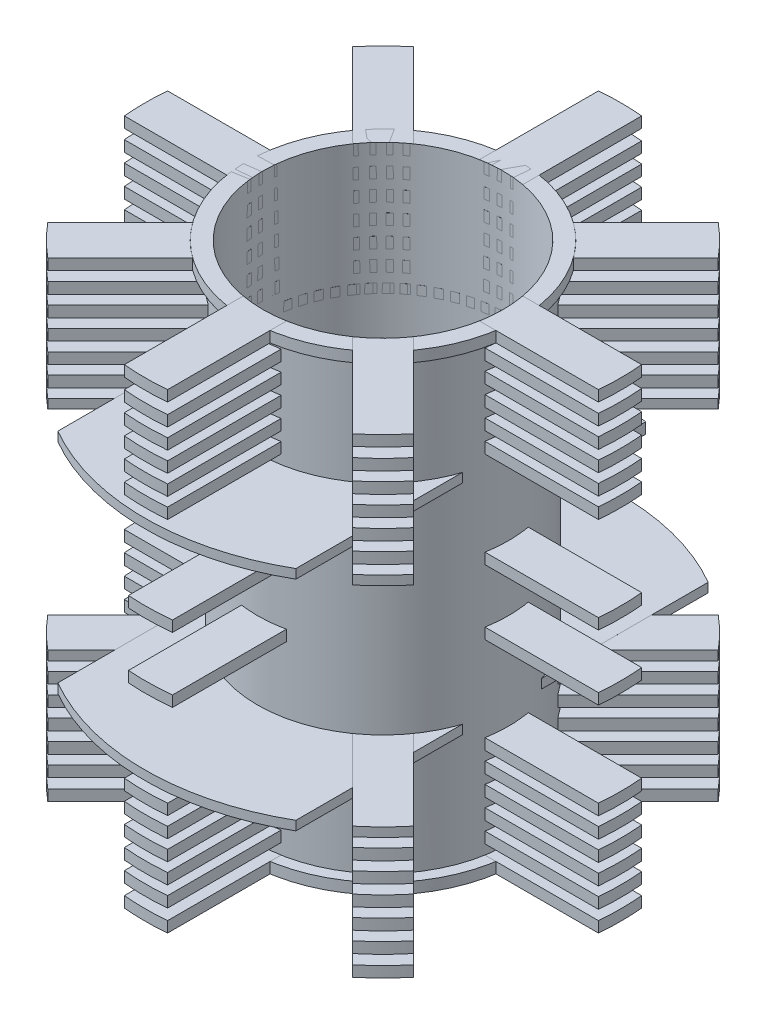
from build123d import *

# Parameters (mm, degrees)
SKETCH1_R                    = 12.6
SKETCH1_R_2                  = 11.1
BOSS_EXTRUDE1_DEPTH          = 1
SKETCH1_3_R                  = 11.6
SKETCH1_3_R_2                = 11.1
BOSS_EXTRUDE2_DEPTH          = 42
BOSS_EXTRUDE7_START          = -11.6
SKETCH8_W                    = 4
SKETCH8_H                    = 1
BOSS_EXTRUDE7_DEPTH          = 24
BOSS_EXTRUDE7_DEPTH_BACK     = 24
SKETCH8_W_2                  = 22
SKETCH8_H_2                  = 0.85
BOSS_EXTRUDE7_2_DEPTH        = 24
BOSS_EXTRUDE7_2_DEPTH_BACK   = 24
BOSS_EXTRUDE7_3_DEPTH        = 24
BOSS_EXTRUDE7_3_DEPTH_BACK   = 24
BOSS_EXTRUDE7_4_DEPTH        = 24
BOSS_EXTRUDE7_4_DEPTH_BACK   = 24
BOSS_EXTRUDE7_5_DEPTH        = 24
BOSS_EXTRUDE7_5_DEPTH_BACK   = 24
BOSS_EXTRUDE7_6_DEPTH        = 24
BOSS_EXTRUDE7_6_DEPTH_BACK   = 24
BOSS_EXTRUDE7_7_DEPTH        = 24
BOSS_EXTRUDE7_7_DEPTH_BACK   = 24
BOSS_EXTRUDE7_8_DEPTH        = 24
BOSS_EXTRUDE7_8_DEPTH_BACK   = 24
BOSS_EXTRUDE7_9_DEPTH        = 24
BOSS_EXTRUDE7_9_DEPTH_BACK   = 24
BOSS_EXTRUDE7_10_DEPTH       = 24
BOSS_EXTRUDE7_10_DEPTH_BACK  = 24
BOSS_EXTRUDE7_11_DEPTH       = 24
BOSS_EXTRUDE7_11_DEPTH_BACK  = 24
BOSS_EXTRUDE7_12_DEPTH       = 24
BOSS_EXTRUDE7_12_DEPTH_BACK  = 24
BOSS_EXTRUDE7_13_DEPTH       = 24
BOSS_EXTRUDE7_13_DEPTH_BACK  = 24
BOSS_EXTRUDE7_14_DEPTH       = 24
BOSS_EXTRUDE7_14_DEPTH_BACK  = 24
BOSS_EXTRUDE7_15_DEPTH       = 24
BOSS_EXTRUDE7_15_DEPTH_BACK  = 24
BOSS_EXTRUDE7_16_DEPTH       = 24
BOSS_EXTRUDE7_16_DEPTH_BACK  = 24
SKETCH11_W                   = 4
SKETCH11_H                   = 1
BOSS_EXTRUDE8_DEPTH          = 25
BOSS_EXTRUDE8_DEPTH_BACK     = 25
SKETCH11_H_2                 = 1.02
BOSS_EXTRUDE8_2_DEPTH        = 25
BOSS_EXTRUDE8_2_DEPTH_BACK   = 25
BOSS_EXTRUDE8_3_DEPTH        = 25
BOSS_EXTRUDE8_3_DEPTH_BACK   = 25
BOSS_EXTRUDE8_4_DEPTH        = 25
BOSS_EXTRUDE8_4_DEPTH_BACK   = 25
BOSS_EXTRUDE8_5_DEPTH        = 25
BOSS_EXTRUDE8_5_DEPTH_BACK   = 25
BOSS_EXTRUDE8_6_DEPTH        = 25
BOSS_EXTRUDE8_6_DEPTH_BACK   = 25
BOSS_EXTRUDE8_7_DEPTH        = 25
BOSS_EXTRUDE8_7_DEPTH_BACK   = 25
BOSS_EXTRUDE8_8_DEPTH        = 25
BOSS_EXTRUDE8_8_DEPTH_BACK   = 25
BOSS_EXTRUDE8_9_DEPTH        = 25
BOSS_EXTRUDE8_9_DEPTH_BACK   = 25
BOSS_EXTRUDE8_10_DEPTH       = 25
BOSS_EXTRUDE8_10_DEPTH_BACK  = 25
BOSS_EXTRUDE8_11_DEPTH       = 25
BOSS_EXTRUDE8_11_DEPTH_BACK  = 25
BOSS_EXTRUDE8_12_DEPTH       = 25
BOSS_EXTRUDE8_12_DEPTH_BACK  = 25
BOSS_EXTRUDE8_13_DEPTH       = 25
BOSS_EXTRUDE8_13_DEPTH_BACK  = 25
BOSS_EXTRUDE8_14_DEPTH       = 25
BOSS_EXTRUDE8_14_DEPTH_BACK  = 25
BOSS_EXTRUDE6_START          = 41.5
SKETCH1_8_R                  = 12.6
SKETCH1_8_R_2                = 11.1
BOSS_EXTRUDE6_DEPTH          = 1
SKETCH35_W                   = 4
SKETCH35_H                   = 1.02
SKETCH35_H_2                 = 1
SKETCH35_H_3                 = 0.85
BOSS_EXTRUDE12_DEPTH         = 25
BOSS_EXTRUDE12_DEPTH_BACK    = 25
SKETCH36_W                   = 4
SKETCH36_H                   = 1.02
BOSS_EXTRUDE13_DEPTH         = 25
BOSS_EXTRUDE13_DEPTH_BACK    = 25
BOSS_EXTRUDE13_2_DEPTH       = 25
BOSS_EXTRUDE13_2_DEPTH_BACK  = 25
BOSS_EXTRUDE13_3_DEPTH       = 25
BOSS_EXTRUDE13_3_DEPTH_BACK  = 25
BOSS_EXTRUDE13_4_DEPTH       = 25
BOSS_EXTRUDE13_4_DEPTH_BACK  = 25
BOSS_EXTRUDE13_5_DEPTH       = 25
BOSS_EXTRUDE13_5_DEPTH_BACK  = 25
SKETCH36_H_2                 = 1
BOSS_EXTRUDE13_6_DEPTH       = 25
BOSS_EXTRUDE13_6_DEPTH_BACK  = 25
SKETCH36_H_3                 = 0.85
BOSS_EXTRUDE13_7_DEPTH       = 25
BOSS_EXTRUDE13_7_DEPTH_BACK  = 25
BOSS_EXTRUDE13_8_DEPTH       = 25
BOSS_EXTRUDE13_8_DEPTH_BACK  = 25
BOSS_EXTRUDE13_9_DEPTH       = 25
BOSS_EXTRUDE13_9_DEPTH_BACK  = 25
BOSS_EXTRUDE13_10_DEPTH      = 25
BOSS_EXTRUDE13_10_DEPTH_BACK = 25
BOSS_EXTRUDE13_11_DEPTH      = 25
BOSS_EXTRUDE13_11_DEPTH_BACK = 25
BOSS_EXTRUDE13_12_DEPTH      = 25
BOSS_EXTRUDE13_12_DEPTH_BACK = 25
BOSS_EXTRUDE13_13_DEPTH      = 25
BOSS_EXTRUDE13_13_DEPTH_BACK = 25
BOSS_EXTRUDE13_14_DEPTH      = 25
BOSS_EXTRUDE13_14_DEPTH_BACK = 25
SKETCH37_R                   = 55.053371744
SKETCH37_R_2                 = 22
CUT_EXTRUDE11_DEPTH          = 1
CUT_EXTRUDE11_DEPTH_BACK     = 44.500303563
SKETCH37_6_R                 = 11.1
CUT_EXTRUDE12_DEPTH          = 1
CUT_EXTRUDE12_DEPTH_BACK     = 44.500303563


with BuildPart() as part:
    # Sketch1 (on Top Plane) → Boss-Extrude1 (new body)
    with BuildSketch(Plane(origin=(0, 0, 0), x_dir=(1, 0, 0), z_dir=(0, 1, 0))):
        Circle(SKETCH1_R)
        Circle(SKETCH1_R_2, mode=Mode.SUBTRACT)
    extrude(amount=-BOSS_EXTRUDE1_DEPTH)

    # Sketch1_3 (on Top Plane) → Boss-Extrude2 (add)
    with BuildSketch(Plane(origin=(0, 0, 0), x_dir=(1, 0, 0), z_dir=(0, 1, 0))):
        Circle(SKETCH1_3_R)
        Circle(SKETCH1_3_R_2, mode=Mode.SUBTRACT)
    extrude(amount=BOSS_EXTRUDE2_DEPTH)


with BuildPart() as body_2:
    # Sketch8 → Boss-Extrude7 (new body, two sides)
    with BuildSketch(Plane(origin=(0, 42, 11.6), x_dir=(1, 0, 0), z_dir=(0, 0, 1)).offset(BOSS_EXTRUDE7_START)) as boss_extrude7_sk:
        with Locations((0.415077538, -18.25)):
            Rectangle(SKETCH8_W, SKETCH8_H)
    extrude(amount=BOSS_EXTRUDE7_DEPTH)
    extrude(boss_extrude7_sk.sketch, amount=-BOSS_EXTRUDE7_DEPTH_BACK)


with BuildPart() as body_3:
    # Sketch8 → Boss-Extrude7 2 (new body, two sides)
    with BuildSketch(Plane(origin=(0, 42, 11.6), x_dir=(1, 0, 0), z_dir=(0, 0, 1)).offset(BOSS_EXTRUDE7_START)) as boss_extrude7_2_sk:
        with Locations((0, -11.175)):
            Rectangle(SKETCH8_W_2, SKETCH8_H_2)
    extrude(amount=BOSS_EXTRUDE7_2_DEPTH)
    extrude(boss_extrude7_2_sk.sketch, amount=-BOSS_EXTRUDE7_2_DEPTH_BACK)


with BuildPart() as body_4:
    # Sketch8 → Boss-Extrude7 3 (new body, two sides)
    with BuildSketch(Plane(origin=(0, 42, 11.6), x_dir=(1, 0, 0), z_dir=(0, 0, 1)).offset(BOSS_EXTRUDE7_START)) as boss_extrude7_3_sk:
        with Locations((0, -9.4)):
            Rectangle(SKETCH8_W, SKETCH8_H)
    extrude(amount=BOSS_EXTRUDE7_3_DEPTH)
    extrude(boss_extrude7_3_sk.sketch, amount=-BOSS_EXTRUDE7_3_DEPTH_BACK)


with BuildPart() as body_5:
    # Sketch8 → Boss-Extrude7 4 (new body, two sides)
    with BuildSketch(Plane(origin=(0, 42, 11.6), x_dir=(1, 0, 0), z_dir=(0, 0, 1)).offset(BOSS_EXTRUDE7_START)) as boss_extrude7_4_sk:
        with Locations((0, -31.325)):
            Rectangle(SKETCH8_W_2, SKETCH8_H_2)
    extrude(amount=BOSS_EXTRUDE7_4_DEPTH)
    extrude(boss_extrude7_4_sk.sketch, amount=-BOSS_EXTRUDE7_4_DEPTH_BACK)


with BuildPart() as body_6:
    # Sketch8 → Boss-Extrude7 5 (new body, two sides)
    with BuildSketch(Plane(origin=(0, 42, 11.6), x_dir=(1, 0, 0), z_dir=(0, 0, 1)).offset(BOSS_EXTRUDE7_START)) as boss_extrude7_5_sk:
        with Locations((0, -7.55)):
            Rectangle(SKETCH8_W, SKETCH8_H)
    extrude(amount=BOSS_EXTRUDE7_5_DEPTH)
    extrude(boss_extrude7_5_sk.sketch, amount=-BOSS_EXTRUDE7_5_DEPTH_BACK)


with BuildPart() as body_7:
    # Sketch8 → Boss-Extrude7 6 (new body, two sides)
    with BuildSketch(Plane(origin=(0, 42, 11.6), x_dir=(1, 0, 0), z_dir=(0, 0, 1)).offset(BOSS_EXTRUDE7_START)) as boss_extrude7_6_sk:
        with Locations((0, -5.7)):
            Rectangle(SKETCH8_W, SKETCH8_H)
    extrude(amount=BOSS_EXTRUDE7_6_DEPTH)
    extrude(boss_extrude7_6_sk.sketch, amount=-BOSS_EXTRUDE7_6_DEPTH_BACK)


with BuildPart() as body_8:
    # Sketch8 → Boss-Extrude7 7 (new body, two sides)
    with BuildSketch(Plane(origin=(0, 42, 11.6), x_dir=(1, 0, 0), z_dir=(0, 0, 1)).offset(BOSS_EXTRUDE7_START)) as boss_extrude7_7_sk:
        with Locations((0, -3.85)):
            Rectangle(SKETCH8_W, SKETCH8_H)
    extrude(amount=BOSS_EXTRUDE7_7_DEPTH)
    extrude(boss_extrude7_7_sk.sketch, amount=-BOSS_EXTRUDE7_7_DEPTH_BACK)


with BuildPart() as body_9:
    # Sketch8 → Boss-Extrude7 8 (new body, two sides)
    with BuildSketch(Plane(origin=(0, 42, 11.6), x_dir=(1, 0, 0), z_dir=(0, 0, 1)).offset(BOSS_EXTRUDE7_START)) as boss_extrude7_8_sk:
        with Locations((0, -2)):
            Rectangle(SKETCH8_W, SKETCH8_H)
    extrude(amount=BOSS_EXTRUDE7_8_DEPTH)
    extrude(boss_extrude7_8_sk.sketch, amount=-BOSS_EXTRUDE7_8_DEPTH_BACK)


with BuildPart() as body_10:
    # Sketch8 → Boss-Extrude7 9 (new body, two sides)
    with BuildSketch(Plane(origin=(0, 42, 11.6), x_dir=(1, 0, 0), z_dir=(0, 0, 1)).offset(BOSS_EXTRUDE7_START)) as boss_extrude7_9_sk:
        with Locations((0, -40.5)):
            Rectangle(SKETCH8_W, SKETCH8_H)
    extrude(amount=BOSS_EXTRUDE7_9_DEPTH)
    extrude(boss_extrude7_9_sk.sketch, amount=-BOSS_EXTRUDE7_9_DEPTH_BACK)


with BuildPart() as body_11:
    # Sketch8 → Boss-Extrude7 10 (new body, two sides)
    with BuildSketch(Plane(origin=(0, 42, 11.6), x_dir=(1, 0, 0), z_dir=(0, 0, 1)).offset(BOSS_EXTRUDE7_START)) as boss_extrude7_10_sk:
        with Locations((0, -38.65)):
            Rectangle(SKETCH8_W, SKETCH8_H)
    extrude(amount=BOSS_EXTRUDE7_10_DEPTH)
    extrude(boss_extrude7_10_sk.sketch, amount=-BOSS_EXTRUDE7_10_DEPTH_BACK)


with BuildPart() as body_12:
    # Sketch8 → Boss-Extrude7 11 (new body, two sides)
    with BuildSketch(Plane(origin=(0, 42, 11.6), x_dir=(1, 0, 0), z_dir=(0, 0, 1)).offset(BOSS_EXTRUDE7_START)) as boss_extrude7_11_sk:
        with Locations((0, -36.8)):
            Rectangle(SKETCH8_W, SKETCH8_H)
    extrude(amount=BOSS_EXTRUDE7_11_DEPTH)
    extrude(boss_extrude7_11_sk.sketch, amount=-BOSS_EXTRUDE7_11_DEPTH_BACK)


with BuildPart() as body_13:
    # Sketch8 → Boss-Extrude7 12 (new body, two sides)
    with BuildSketch(Plane(origin=(0, 42, 11.6), x_dir=(1, 0, 0), z_dir=(0, 0, 1)).offset(BOSS_EXTRUDE7_START)) as boss_extrude7_12_sk:
        with Locations((0, -34.95)):
            Rectangle(SKETCH8_W, SKETCH8_H)
    extrude(amount=BOSS_EXTRUDE7_12_DEPTH)
    extrude(boss_extrude7_12_sk.sketch, amount=-BOSS_EXTRUDE7_12_DEPTH_BACK)


with BuildPart() as body_14:
    # Sketch8 → Boss-Extrude7 13 (new body, two sides)
    with BuildSketch(Plane(origin=(0, 42, 11.6), x_dir=(1, 0, 0), z_dir=(0, 0, 1)).offset(BOSS_EXTRUDE7_START)) as boss_extrude7_13_sk:
        with Locations((0, -33.1)):
            Rectangle(SKETCH8_W, SKETCH8_H)
    extrude(amount=BOSS_EXTRUDE7_13_DEPTH)
    extrude(boss_extrude7_13_sk.sketch, amount=-BOSS_EXTRUDE7_13_DEPTH_BACK)


with BuildPart() as body_15:
    # Sketch8 → Boss-Extrude7 14 (new body, two sides)
    with BuildSketch(Plane(origin=(0, 42, 11.6), x_dir=(1, 0, 0), z_dir=(0, 0, 1)).offset(BOSS_EXTRUDE7_START)) as boss_extrude7_14_sk:
        with Locations((0.415077538, -24.25)):
            Rectangle(SKETCH8_W, SKETCH8_H)
    extrude(amount=BOSS_EXTRUDE7_14_DEPTH)
    extrude(boss_extrude7_14_sk.sketch, amount=-BOSS_EXTRUDE7_14_DEPTH_BACK)


with BuildPart() as body_16:
    # Sketch8 → Boss-Extrude7 15 (new body, two sides)
    with BuildSketch(Plane(origin=(0, 42, 11.6), x_dir=(1, 0, 0), z_dir=(0, 0, 1)).offset(BOSS_EXTRUDE7_START)) as boss_extrude7_15_sk:
        with Locations((0, -42.5)):
            Rectangle(SKETCH8_W, SKETCH8_H)
    extrude(amount=BOSS_EXTRUDE7_15_DEPTH)
    extrude(boss_extrude7_15_sk.sketch, amount=-BOSS_EXTRUDE7_15_DEPTH_BACK)


with BuildPart() as body_17:
    # Sketch8 → Boss-Extrude7 16 (new body, two sides)
    with BuildSketch(Plane(origin=(0, 42, 11.6), x_dir=(1, 0, 0), z_dir=(0, 0, 1)).offset(BOSS_EXTRUDE7_START)) as boss_extrude7_16_sk:
        Rectangle(SKETCH8_W, SKETCH8_H)
    extrude(amount=BOSS_EXTRUDE7_16_DEPTH)
    extrude(boss_extrude7_16_sk.sketch, amount=-BOSS_EXTRUDE7_16_DEPTH_BACK)


with BuildPart() as body_18:
    # Sketch11 → Boss-Extrude8 (new body, two sides)
    with BuildSketch(Plane(origin=(0, 0, 0), x_dir=(0, 0, -1), z_dir=(1, 0, 0))) as boss_extrude8_sk:
        with Locations((0, 23.75)):
            Rectangle(SKETCH11_W, SKETCH11_H)
    extrude(amount=BOSS_EXTRUDE8_DEPTH)
    extrude(boss_extrude8_sk.sketch, amount=-BOSS_EXTRUDE8_DEPTH_BACK)


with BuildPart() as body_19:
    # Sketch11 → Boss-Extrude8 2 (new body, two sides)
    with BuildSketch(Plane(origin=(0, 0, 0), x_dir=(0, 0, -1), z_dir=(1, 0, 0))) as boss_extrude8_2_sk:
        with Locations((0, 32.61)):
            Rectangle(SKETCH11_W, SKETCH11_H_2)
    extrude(amount=BOSS_EXTRUDE8_2_DEPTH)
    extrude(boss_extrude8_2_sk.sketch, amount=-BOSS_EXTRUDE8_2_DEPTH_BACK)


with BuildPart() as body_20:
    # Sketch11 → Boss-Extrude8 3 (new body, two sides)
    with BuildSketch(Plane(origin=(0, 0, 0), x_dir=(0, 0, -1), z_dir=(1, 0, 0))) as boss_extrude8_3_sk:
        with Locations((0, 34.48)):
            Rectangle(SKETCH11_W, SKETCH11_H_2)
    extrude(amount=BOSS_EXTRUDE8_3_DEPTH)
    extrude(boss_extrude8_3_sk.sketch, amount=-BOSS_EXTRUDE8_3_DEPTH_BACK)


with BuildPart() as body_21:
    # Sketch11 → Boss-Extrude8 4 (new body, two sides)
    with BuildSketch(Plane(origin=(0, 0, 0), x_dir=(0, 0, -1), z_dir=(1, 0, 0))) as boss_extrude8_4_sk:
        with Locations((0, 36.35)):
            Rectangle(SKETCH11_W, SKETCH11_H_2)
    extrude(amount=BOSS_EXTRUDE8_4_DEPTH)
    extrude(boss_extrude8_4_sk.sketch, amount=-BOSS_EXTRUDE8_4_DEPTH_BACK)


with BuildPart() as body_22:
    # Sketch11 → Boss-Extrude8 5 (new body, two sides)
    with BuildSketch(Plane(origin=(0, 0, 0), x_dir=(0, 0, -1), z_dir=(1, 0, 0))) as boss_extrude8_5_sk:
        with Locations((0, 38.22)):
            Rectangle(SKETCH11_W, SKETCH11_H_2)
    extrude(amount=BOSS_EXTRUDE8_5_DEPTH)
    extrude(boss_extrude8_5_sk.sketch, amount=-BOSS_EXTRUDE8_5_DEPTH_BACK)


with BuildPart() as body_23:
    # Sketch11 → Boss-Extrude8 6 (new body, two sides)
    with BuildSketch(Plane(origin=(0, 0, 0), x_dir=(0, 0, -1), z_dir=(1, 0, 0))) as boss_extrude8_6_sk:
        with Locations((0, 40.09)):
            Rectangle(SKETCH11_W, SKETCH11_H_2)
    extrude(amount=BOSS_EXTRUDE8_6_DEPTH)
    extrude(boss_extrude8_6_sk.sketch, amount=-BOSS_EXTRUDE8_6_DEPTH_BACK)


with BuildPart() as body_24:
    # Sketch11 → Boss-Extrude8 7 (new body, two sides)
    with BuildSketch(Plane(origin=(0, 0, 0), x_dir=(0, 0, -1), z_dir=(1, 0, 0))) as boss_extrude8_7_sk:
        with Locations((0, 17.75)):
            Rectangle(SKETCH11_W, SKETCH11_H)
    extrude(amount=BOSS_EXTRUDE8_7_DEPTH)
    extrude(boss_extrude8_7_sk.sketch, amount=-BOSS_EXTRUDE8_7_DEPTH_BACK)


with BuildPart() as body_25:
    # Sketch11 → Boss-Extrude8 8 (new body, two sides)
    with BuildSketch(Plane(origin=(0, 0, 0), x_dir=(0, 0, -1), z_dir=(1, 0, 0))) as boss_extrude8_8_sk:
        with Locations((0, 42)):
            Rectangle(SKETCH11_W, SKETCH11_H)
    extrude(amount=BOSS_EXTRUDE8_8_DEPTH)
    extrude(boss_extrude8_8_sk.sketch, amount=-BOSS_EXTRUDE8_8_DEPTH_BACK)


with BuildPart() as body_26:
    # Sketch11 → Boss-Extrude8 9 (new body, two sides)
    with BuildSketch(Plane(origin=(0, 0, 0), x_dir=(0, 0, -1), z_dir=(1, 0, 0))) as boss_extrude8_9_sk:
        with Locations((0, -0.5)):
            Rectangle(SKETCH11_W, SKETCH11_H)
    extrude(amount=BOSS_EXTRUDE8_9_DEPTH)
    extrude(boss_extrude8_9_sk.sketch, amount=-BOSS_EXTRUDE8_9_DEPTH_BACK)


with BuildPart() as body_27:
    # Sketch11 → Boss-Extrude8 10 (new body, two sides)
    with BuildSketch(Plane(origin=(0, 0, 0), x_dir=(0, 0, -1), z_dir=(1, 0, 0))) as boss_extrude8_10_sk:
        with Locations((0, 1.41)):
            Rectangle(SKETCH11_W, SKETCH11_H_2)
    extrude(amount=BOSS_EXTRUDE8_10_DEPTH)
    extrude(boss_extrude8_10_sk.sketch, amount=-BOSS_EXTRUDE8_10_DEPTH_BACK)


with BuildPart() as body_28:
    # Sketch11 → Boss-Extrude8 11 (new body, two sides)
    with BuildSketch(Plane(origin=(0, 0, 0), x_dir=(0, 0, -1), z_dir=(1, 0, 0))) as boss_extrude8_11_sk:
        with Locations((0, 3.28)):
            Rectangle(SKETCH11_W, SKETCH11_H_2)
    extrude(amount=BOSS_EXTRUDE8_11_DEPTH)
    extrude(boss_extrude8_11_sk.sketch, amount=-BOSS_EXTRUDE8_11_DEPTH_BACK)


with BuildPart() as body_29:
    # Sketch11 → Boss-Extrude8 12 (new body, two sides)
    with BuildSketch(Plane(origin=(0, 0, 0), x_dir=(0, 0, -1), z_dir=(1, 0, 0))) as boss_extrude8_12_sk:
        with Locations((0, 5.15)):
            Rectangle(SKETCH11_W, SKETCH11_H_2)
    extrude(amount=BOSS_EXTRUDE8_12_DEPTH)
    extrude(boss_extrude8_12_sk.sketch, amount=-BOSS_EXTRUDE8_12_DEPTH_BACK)


with BuildPart() as body_30:
    # Sketch11 → Boss-Extrude8 13 (new body, two sides)
    with BuildSketch(Plane(origin=(0, 0, 0), x_dir=(0, 0, -1), z_dir=(1, 0, 0))) as boss_extrude8_13_sk:
        with Locations((0, 7.02)):
            Rectangle(SKETCH11_W, SKETCH11_H_2)
    extrude(amount=BOSS_EXTRUDE8_13_DEPTH)
    extrude(boss_extrude8_13_sk.sketch, amount=-BOSS_EXTRUDE8_13_DEPTH_BACK)


with BuildPart() as body_31:
    # Sketch11 → Boss-Extrude8 14 (new body, two sides)
    with BuildSketch(Plane(origin=(0, 0, 0), x_dir=(0, 0, -1), z_dir=(1, 0, 0))) as boss_extrude8_14_sk:
        with Locations((0, 8.89)):
            Rectangle(SKETCH11_W, SKETCH11_H_2)
    extrude(amount=BOSS_EXTRUDE8_14_DEPTH)
    extrude(boss_extrude8_14_sk.sketch, amount=-BOSS_EXTRUDE8_14_DEPTH_BACK)


with BuildPart() as body_32:
    # Sketch1_8 → Boss-Extrude6 (new body)
    with BuildSketch(Plane(origin=(0, 0, 0), x_dir=(1, 0, 0), z_dir=(0, 1, 0)).offset(BOSS_EXTRUDE6_START)):
        Circle(SKETCH1_8_R)
        Circle(SKETCH1_8_R_2, mode=Mode.SUBTRACT)
    extrude(amount=BOSS_EXTRUDE6_DEPTH)


    add(part.part)  # Boss-Extrude12 merges part
    # Sketch35 → Boss-Extrude12 (add, two sides)
    with BuildSketch(Plane(origin=(0, 0, 0), x_dir=(0.707106781, 0, 0.707106781), z_dir=(-0.707106781, 0, 0.707106781))) as boss_extrude12_sk:
        with Locations((0, 32.609696437)):
            Rectangle(SKETCH35_W, SKETCH35_H)
        with Locations((0, 34.479696437)):
            Rectangle(SKETCH35_W, SKETCH35_H)
        with Locations((0, 36.349696437)):
            Rectangle(SKETCH35_W, SKETCH35_H)
        with Locations((0, 38.219696437)):
            Rectangle(SKETCH35_W, SKETCH35_H)
        with Locations((0, 40.089696437)):
            Rectangle(SKETCH35_W, SKETCH35_H)
        with Locations((0, 41.999696437)):
            Rectangle(SKETCH35_W, SKETCH35_H_2)
        with Locations((0, 30.824696437)):
            Rectangle(SKETCH35_W, SKETCH35_H_3)
        with Locations((0, 10.674696437)):
            Rectangle(SKETCH35_W, SKETCH35_H_3)
        with Locations((0, -0.500303563)):
            Rectangle(SKETCH35_W, SKETCH35_H_2)
        with Locations((0, 1.409696437)):
            Rectangle(SKETCH35_W, SKETCH35_H)
        with Locations((0, 3.279696437)):
            Rectangle(SKETCH35_W, SKETCH35_H)
        with Locations((0, 5.149696437)):
            Rectangle(SKETCH35_W, SKETCH35_H)
        with Locations((0, 7.019696437)):
            Rectangle(SKETCH35_W, SKETCH35_H)
        with Locations((0, 8.889696437)):
            Rectangle(SKETCH35_W, SKETCH35_H)
    extrude(amount=BOSS_EXTRUDE12_DEPTH)
    extrude(boss_extrude12_sk.sketch, amount=-BOSS_EXTRUDE12_DEPTH_BACK)


with BuildPart() as body_32_2:
    # Sketch36 → Boss-Extrude13 (new body, two sides)
    with BuildSketch(Plane(origin=(0, 0, 0), x_dir=(0.707106781, 0, -0.707106781), z_dir=(0.707106781, 0, 0.707106781))) as boss_extrude13_sk:
        with Locations((0, 32.61)):
            Rectangle(SKETCH36_W, SKETCH36_H)
    extrude(amount=BOSS_EXTRUDE13_DEPTH)
    extrude(boss_extrude13_sk.sketch, amount=-BOSS_EXTRUDE13_DEPTH_BACK)


with BuildPart() as body_33:
    # Sketch36 → Boss-Extrude13 2 (new body, two sides)
    with BuildSketch(Plane(origin=(0, 0, 0), x_dir=(0.707106781, 0, -0.707106781), z_dir=(0.707106781, 0, 0.707106781))) as boss_extrude13_2_sk:
        with Locations((0, 34.48)):
            Rectangle(SKETCH36_W, SKETCH36_H)
    extrude(amount=BOSS_EXTRUDE13_2_DEPTH)
    extrude(boss_extrude13_2_sk.sketch, amount=-BOSS_EXTRUDE13_2_DEPTH_BACK)


with BuildPart() as body_34:
    # Sketch36 → Boss-Extrude13 3 (new body, two sides)
    with BuildSketch(Plane(origin=(0, 0, 0), x_dir=(0.707106781, 0, -0.707106781), z_dir=(0.707106781, 0, 0.707106781))) as boss_extrude13_3_sk:
        with Locations((0, 36.35)):
            Rectangle(SKETCH36_W, SKETCH36_H)
    extrude(amount=BOSS_EXTRUDE13_3_DEPTH)
    extrude(boss_extrude13_3_sk.sketch, amount=-BOSS_EXTRUDE13_3_DEPTH_BACK)


with BuildPart() as body_35:
    # Sketch36 → Boss-Extrude13 4 (new body, two sides)
    with BuildSketch(Plane(origin=(0, 0, 0), x_dir=(0.707106781, 0, -0.707106781), z_dir=(0.707106781, 0, 0.707106781))) as boss_extrude13_4_sk:
        with Locations((0, 38.22)):
            Rectangle(SKETCH36_W, SKETCH36_H)
    extrude(amount=BOSS_EXTRUDE13_4_DEPTH)
    extrude(boss_extrude13_4_sk.sketch, amount=-BOSS_EXTRUDE13_4_DEPTH_BACK)


with BuildPart() as body_36:
    # Sketch36 → Boss-Extrude13 5 (new body, two sides)
    with BuildSketch(Plane(origin=(0, 0, 0), x_dir=(0.707106781, 0, -0.707106781), z_dir=(0.707106781, 0, 0.707106781))) as boss_extrude13_5_sk:
        with Locations((0, 40.09)):
            Rectangle(SKETCH36_W, SKETCH36_H)
    extrude(amount=BOSS_EXTRUDE13_5_DEPTH)
    extrude(boss_extrude13_5_sk.sketch, amount=-BOSS_EXTRUDE13_5_DEPTH_BACK)


with BuildPart() as body_37:
    # Sketch36 → Boss-Extrude13 6 (new body, two sides)
    with BuildSketch(Plane(origin=(0, 0, 0), x_dir=(0.707106781, 0, -0.707106781), z_dir=(0.707106781, 0, 0.707106781))) as boss_extrude13_6_sk:
        with Locations((0, 42)):
            Rectangle(SKETCH36_W, SKETCH36_H_2)
    extrude(amount=BOSS_EXTRUDE13_6_DEPTH)
    extrude(boss_extrude13_6_sk.sketch, amount=-BOSS_EXTRUDE13_6_DEPTH_BACK)


with BuildPart() as body_38:
    # Sketch36 → Boss-Extrude13 7 (new body, two sides)
    with BuildSketch(Plane(origin=(0, 0, 0), x_dir=(0.707106781, 0, -0.707106781), z_dir=(0.707106781, 0, 0.707106781))) as boss_extrude13_7_sk:
        with Locations((0, 30.825)):
            Rectangle(SKETCH36_W, SKETCH36_H_3)
    extrude(amount=BOSS_EXTRUDE13_7_DEPTH)
    extrude(boss_extrude13_7_sk.sketch, amount=-BOSS_EXTRUDE13_7_DEPTH_BACK)


with BuildPart() as body_39:
    # Sketch36 → Boss-Extrude13 8 (new body, two sides)
    with BuildSketch(Plane(origin=(0, 0, 0), x_dir=(0.707106781, 0, -0.707106781), z_dir=(0.707106781, 0, 0.707106781))) as boss_extrude13_8_sk:
        with Locations((0, 10.675)):
            Rectangle(SKETCH36_W, SKETCH36_H_3)
    extrude(amount=BOSS_EXTRUDE13_8_DEPTH)
    extrude(boss_extrude13_8_sk.sketch, amount=-BOSS_EXTRUDE13_8_DEPTH_BACK)


with BuildPart() as body_40:
    # Sketch36 → Boss-Extrude13 9 (new body, two sides)
    with BuildSketch(Plane(origin=(0, 0, 0), x_dir=(0.707106781, 0, -0.707106781), z_dir=(0.707106781, 0, 0.707106781))) as boss_extrude13_9_sk:
        with Locations((0, -0.5)):
            Rectangle(SKETCH36_W, SKETCH36_H_2)
    extrude(amount=BOSS_EXTRUDE13_9_DEPTH)
    extrude(boss_extrude13_9_sk.sketch, amount=-BOSS_EXTRUDE13_9_DEPTH_BACK)


with BuildPart() as body_41:
    # Sketch36 → Boss-Extrude13 10 (new body, two sides)
    with BuildSketch(Plane(origin=(0, 0, 0), x_dir=(0.707106781, 0, -0.707106781), z_dir=(0.707106781, 0, 0.707106781))) as boss_extrude13_10_sk:
        with Locations((0, 1.41)):
            Rectangle(SKETCH36_W, SKETCH36_H)
    extrude(amount=BOSS_EXTRUDE13_10_DEPTH)
    extrude(boss_extrude13_10_sk.sketch, amount=-BOSS_EXTRUDE13_10_DEPTH_BACK)


with BuildPart() as body_42:
    # Sketch36 → Boss-Extrude13 11 (new body, two sides)
    with BuildSketch(Plane(origin=(0, 0, 0), x_dir=(0.707106781, 0, -0.707106781), z_dir=(0.707106781, 0, 0.707106781))) as boss_extrude13_11_sk:
        with Locations((0, 3.28)):
            Rectangle(SKETCH36_W, SKETCH36_H)
    extrude(amount=BOSS_EXTRUDE13_11_DEPTH)
    extrude(boss_extrude13_11_sk.sketch, amount=-BOSS_EXTRUDE13_11_DEPTH_BACK)


with BuildPart() as body_43:
    # Sketch36 → Boss-Extrude13 12 (new body, two sides)
    with BuildSketch(Plane(origin=(0, 0, 0), x_dir=(0.707106781, 0, -0.707106781), z_dir=(0.707106781, 0, 0.707106781))) as boss_extrude13_12_sk:
        with Locations((0, 5.15)):
            Rectangle(SKETCH36_W, SKETCH36_H)
    extrude(amount=BOSS_EXTRUDE13_12_DEPTH)
    extrude(boss_extrude13_12_sk.sketch, amount=-BOSS_EXTRUDE13_12_DEPTH_BACK)


with BuildPart() as body_44:
    # Sketch36 → Boss-Extrude13 13 (new body, two sides)
    with BuildSketch(Plane(origin=(0, 0, 0), x_dir=(0.707106781, 0, -0.707106781), z_dir=(0.707106781, 0, 0.707106781))) as boss_extrude13_13_sk:
        with Locations((0, 7.02)):
            Rectangle(SKETCH36_W, SKETCH36_H)
    extrude(amount=BOSS_EXTRUDE13_13_DEPTH)
    extrude(boss_extrude13_13_sk.sketch, amount=-BOSS_EXTRUDE13_13_DEPTH_BACK)


with BuildPart() as body_45:
    # Sketch36 → Boss-Extrude13 14 (new body, two sides)
    with BuildSketch(Plane(origin=(0, 0, 0), x_dir=(0.707106781, 0, -0.707106781), z_dir=(0.707106781, 0, 0.707106781))) as boss_extrude13_14_sk:
        with Locations((0, 8.89)):
            Rectangle(SKETCH36_W, SKETCH36_H)
    extrude(amount=BOSS_EXTRUDE13_14_DEPTH)
    extrude(boss_extrude13_14_sk.sketch, amount=-BOSS_EXTRUDE13_14_DEPTH_BACK)


with BuildPart() as cut_extrude11_tool:
    # Sketch37 → Cut-Extrude11 (new body, two sides)
    with BuildSketch(Plane(origin=(0, 42.5, 0), x_dir=(1, 0, 0), z_dir=(0, 1, 0))) as cut_extrude11_sk:
        Circle(SKETCH37_R)
        Circle(SKETCH37_R_2, mode=Mode.SUBTRACT)
    extrude(amount=CUT_EXTRUDE11_DEPTH)
    extrude(cut_extrude11_sk.sketch, amount=-CUT_EXTRUDE11_DEPTH_BACK)


with BuildPart() as body_2_1:
    add(body_2.part)

    # Cut-Extrude11: cut by cut_extrude11_tool
    add(cut_extrude11_tool.part, mode=Mode.SUBTRACT)


with BuildPart() as body_3_1:
    add(body_3.part)

    # Cut-Extrude11: cut by cut_extrude11_tool
    add(cut_extrude11_tool.part, mode=Mode.SUBTRACT)


with BuildPart() as body_4_1:
    add(body_4.part)

    # Cut-Extrude11: cut by cut_extrude11_tool
    add(cut_extrude11_tool.part, mode=Mode.SUBTRACT)


with BuildPart() as body_5_1:
    add(body_5.part)

    # Cut-Extrude11: cut by cut_extrude11_tool
    add(cut_extrude11_tool.part, mode=Mode.SUBTRACT)


with BuildPart() as body_6_1:
    add(body_6.part)

    # Cut-Extrude11: cut by cut_extrude11_tool
    add(cut_extrude11_tool.part, mode=Mode.SUBTRACT)


with BuildPart() as body_7_1:
    add(body_7.part)

    # Cut-Extrude11: cut by cut_extrude11_tool
    add(cut_extrude11_tool.part, mode=Mode.SUBTRACT)


with BuildPart() as body_8_1:
    add(body_8.part)

    # Cut-Extrude11: cut by cut_extrude11_tool
    add(cut_extrude11_tool.part, mode=Mode.SUBTRACT)


with BuildPart() as body_9_1:
    add(body_9.part)

    # Cut-Extrude11: cut by cut_extrude11_tool
    add(cut_extrude11_tool.part, mode=Mode.SUBTRACT)


with BuildPart() as body_10_1:
    add(body_10.part)

    # Cut-Extrude11: cut by cut_extrude11_tool
    add(cut_extrude11_tool.part, mode=Mode.SUBTRACT)


with BuildPart() as body_11_1:
    add(body_11.part)

    # Cut-Extrude11: cut by cut_extrude11_tool
    add(cut_extrude11_tool.part, mode=Mode.SUBTRACT)


with BuildPart() as body_12_1:
    add(body_12.part)

    # Cut-Extrude11: cut by cut_extrude11_tool
    add(cut_extrude11_tool.part, mode=Mode.SUBTRACT)


with BuildPart() as body_13_1:
    add(body_13.part)

    # Cut-Extrude11: cut by cut_extrude11_tool
    add(cut_extrude11_tool.part, mode=Mode.SUBTRACT)


with BuildPart() as body_14_1:
    add(body_14.part)

    # Cut-Extrude11: cut by cut_extrude11_tool
    add(cut_extrude11_tool.part, mode=Mode.SUBTRACT)


with BuildPart() as body_15_1:
    add(body_15.part)

    # Cut-Extrude11: cut by cut_extrude11_tool
    add(cut_extrude11_tool.part, mode=Mode.SUBTRACT)


with BuildPart() as body_16_1:
    add(body_16.part)

    # Cut-Extrude11: cut by cut_extrude11_tool
    add(cut_extrude11_tool.part, mode=Mode.SUBTRACT)


with BuildPart() as body_17_1:
    add(body_17.part)

    # Cut-Extrude11: cut by cut_extrude11_tool
    add(cut_extrude11_tool.part, mode=Mode.SUBTRACT)


with BuildPart() as body_18_1:
    add(body_18.part)

    # Cut-Extrude11: cut by cut_extrude11_tool
    add(cut_extrude11_tool.part, mode=Mode.SUBTRACT)


with BuildPart() as body_19_1:
    add(body_19.part)

    # Cut-Extrude11: cut by cut_extrude11_tool
    add(cut_extrude11_tool.part, mode=Mode.SUBTRACT)


with BuildPart() as body_20_1:
    add(body_20.part)

    # Cut-Extrude11: cut by cut_extrude11_tool
    add(cut_extrude11_tool.part, mode=Mode.SUBTRACT)


with BuildPart() as body_21_1:
    add(body_21.part)

    # Cut-Extrude11: cut by cut_extrude11_tool
    add(cut_extrude11_tool.part, mode=Mode.SUBTRACT)


with BuildPart() as body_22_1:
    add(body_22.part)

    # Cut-Extrude11: cut by cut_extrude11_tool
    add(cut_extrude11_tool.part, mode=Mode.SUBTRACT)


with BuildPart() as body_23_1:
    add(body_23.part)

    # Cut-Extrude11: cut by cut_extrude11_tool
    add(cut_extrude11_tool.part, mode=Mode.SUBTRACT)


with BuildPart() as body_24_1:
    add(body_24.part)

    # Cut-Extrude11: cut by cut_extrude11_tool
    add(cut_extrude11_tool.part, mode=Mode.SUBTRACT)


with BuildPart() as body_25_1:
    add(body_25.part)

    # Cut-Extrude11: cut by cut_extrude11_tool
    add(cut_extrude11_tool.part, mode=Mode.SUBTRACT)


with BuildPart() as body_26_1:
    add(body_26.part)

    # Cut-Extrude11: cut by cut_extrude11_tool
    add(cut_extrude11_tool.part, mode=Mode.SUBTRACT)


with BuildPart() as body_27_1:
    add(body_27.part)

    # Cut-Extrude11: cut by cut_extrude11_tool
    add(cut_extrude11_tool.part, mode=Mode.SUBTRACT)


with BuildPart() as body_28_1:
    add(body_28.part)

    # Cut-Extrude11: cut by cut_extrude11_tool
    add(cut_extrude11_tool.part, mode=Mode.SUBTRACT)


with BuildPart() as body_29_1:
    add(body_29.part)

    # Cut-Extrude11: cut by cut_extrude11_tool
    add(cut_extrude11_tool.part, mode=Mode.SUBTRACT)


with BuildPart() as body_30_1:
    add(body_30.part)

    # Cut-Extrude11: cut by cut_extrude11_tool
    add(cut_extrude11_tool.part, mode=Mode.SUBTRACT)


with BuildPart() as body_31_1:
    add(body_31.part)

    # Cut-Extrude11: cut by cut_extrude11_tool
    add(cut_extrude11_tool.part, mode=Mode.SUBTRACT)


with BuildPart() as body_32_1:
    add(body_32.part)

    # Cut-Extrude11: cut by cut_extrude11_tool
    add(cut_extrude11_tool.part, mode=Mode.SUBTRACT)


with BuildPart() as body_32_2_1:
    add(body_32_2.part)

    # Cut-Extrude11: cut by cut_extrude11_tool
    add(cut_extrude11_tool.part, mode=Mode.SUBTRACT)


with BuildPart() as body_33_1:
    add(body_33.part)

    # Cut-Extrude11: cut by cut_extrude11_tool
    add(cut_extrude11_tool.part, mode=Mode.SUBTRACT)


with BuildPart() as body_34_1:
    add(body_34.part)

    # Cut-Extrude11: cut by cut_extrude11_tool
    add(cut_extrude11_tool.part, mode=Mode.SUBTRACT)


with BuildPart() as body_35_1:
    add(body_35.part)

    # Cut-Extrude11: cut by cut_extrude11_tool
    add(cut_extrude11_tool.part, mode=Mode.SUBTRACT)


with BuildPart() as body_36_1:
    add(body_36.part)

    # Cut-Extrude11: cut by cut_extrude11_tool
    add(cut_extrude11_tool.part, mode=Mode.SUBTRACT)


with BuildPart() as body_37_1:
    add(body_37.part)

    # Cut-Extrude11: cut by cut_extrude11_tool
    add(cut_extrude11_tool.part, mode=Mode.SUBTRACT)


with BuildPart() as body_38_1:
    add(body_38.part)

    # Cut-Extrude11: cut by cut_extrude11_tool
    add(cut_extrude11_tool.part, mode=Mode.SUBTRACT)


with BuildPart() as body_39_1:
    add(body_39.part)

    # Cut-Extrude11: cut by cut_extrude11_tool
    add(cut_extrude11_tool.part, mode=Mode.SUBTRACT)


with BuildPart() as body_40_1:
    add(body_40.part)

    # Cut-Extrude11: cut by cut_extrude11_tool
    add(cut_extrude11_tool.part, mode=Mode.SUBTRACT)


with BuildPart() as body_41_1:
    add(body_41.part)

    # Cut-Extrude11: cut by cut_extrude11_tool
    add(cut_extrude11_tool.part, mode=Mode.SUBTRACT)


with BuildPart() as body_42_1:
    add(body_42.part)

    # Cut-Extrude11: cut by cut_extrude11_tool
    add(cut_extrude11_tool.part, mode=Mode.SUBTRACT)


with BuildPart() as body_43_1:
    add(body_43.part)

    # Cut-Extrude11: cut by cut_extrude11_tool
    add(cut_extrude11_tool.part, mode=Mode.SUBTRACT)


with BuildPart() as body_44_1:
    add(body_44.part)

    # Cut-Extrude11: cut by cut_extrude11_tool
    add(cut_extrude11_tool.part, mode=Mode.SUBTRACT)


with BuildPart() as body_45_1:
    add(body_45.part)

    # Cut-Extrude11: cut by cut_extrude11_tool
    add(cut_extrude11_tool.part, mode=Mode.SUBTRACT)


with BuildPart() as cut_extrude12_tool:
    # Sketch37_6 → Cut-Extrude12 (new body, two sides)
    with BuildSketch(Plane(origin=(0, 42.5, 0), x_dir=(1, 0, 0), z_dir=(0, 1, 0))) as cut_extrude12_sk:
        Circle(SKETCH37_6_R)
    extrude(amount=CUT_EXTRUDE12_DEPTH)
    extrude(cut_extrude12_sk.sketch, amount=-CUT_EXTRUDE12_DEPTH_BACK)


with BuildPart() as body_2_2:
    add(body_2_1.part)

    # Cut-Extrude12: cut by cut_extrude12_tool
    add(cut_extrude12_tool.part, mode=Mode.SUBTRACT)


with BuildPart() as body_3_2:
    add(body_3_1.part)

    # Cut-Extrude12: cut by cut_extrude12_tool
    add(cut_extrude12_tool.part, mode=Mode.SUBTRACT)


with BuildPart() as body_4_2:
    add(body_4_1.part)

    # Cut-Extrude12: cut by cut_extrude12_tool
    add(cut_extrude12_tool.part, mode=Mode.SUBTRACT)


with BuildPart() as body_5_2:
    add(body_5_1.part)

    # Cut-Extrude12: cut by cut_extrude12_tool
    add(cut_extrude12_tool.part, mode=Mode.SUBTRACT)


with BuildPart() as body_6_2:
    add(body_6_1.part)

    # Cut-Extrude12: cut by cut_extrude12_tool
    add(cut_extrude12_tool.part, mode=Mode.SUBTRACT)


with BuildPart() as body_7_2:
    add(body_7_1.part)

    # Cut-Extrude12: cut by cut_extrude12_tool
    add(cut_extrude12_tool.part, mode=Mode.SUBTRACT)


with BuildPart() as body_8_2:
    add(body_8_1.part)

    # Cut-Extrude12: cut by cut_extrude12_tool
    add(cut_extrude12_tool.part, mode=Mode.SUBTRACT)


with BuildPart() as body_9_2:
    add(body_9_1.part)

    # Cut-Extrude12: cut by cut_extrude12_tool
    add(cut_extrude12_tool.part, mode=Mode.SUBTRACT)


with BuildPart() as body_10_2:
    add(body_10_1.part)

    # Cut-Extrude12: cut by cut_extrude12_tool
    add(cut_extrude12_tool.part, mode=Mode.SUBTRACT)


with BuildPart() as body_11_2:
    add(body_11_1.part)

    # Cut-Extrude12: cut by cut_extrude12_tool
    add(cut_extrude12_tool.part, mode=Mode.SUBTRACT)


with BuildPart() as body_12_2:
    add(body_12_1.part)

    # Cut-Extrude12: cut by cut_extrude12_tool
    add(cut_extrude12_tool.part, mode=Mode.SUBTRACT)


with BuildPart() as body_13_2:
    add(body_13_1.part)

    # Cut-Extrude12: cut by cut_extrude12_tool
    add(cut_extrude12_tool.part, mode=Mode.SUBTRACT)


with BuildPart() as body_14_2:
    add(body_14_1.part)

    # Cut-Extrude12: cut by cut_extrude12_tool
    add(cut_extrude12_tool.part, mode=Mode.SUBTRACT)


with BuildPart() as body_15_2:
    add(body_15_1.part)

    # Cut-Extrude12: cut by cut_extrude12_tool
    add(cut_extrude12_tool.part, mode=Mode.SUBTRACT)


with BuildPart() as body_16_2:
    add(body_16_1.part)

    # Cut-Extrude12: cut by cut_extrude12_tool
    add(cut_extrude12_tool.part, mode=Mode.SUBTRACT)


with BuildPart() as body_17_2:
    add(body_17_1.part)

    # Cut-Extrude12: cut by cut_extrude12_tool
    add(cut_extrude12_tool.part, mode=Mode.SUBTRACT)


with BuildPart() as body_18_2:
    add(body_18_1.part)

    # Cut-Extrude12: cut by cut_extrude12_tool
    add(cut_extrude12_tool.part, mode=Mode.SUBTRACT)


with BuildPart() as body_19_2:
    add(body_19_1.part)

    # Cut-Extrude12: cut by cut_extrude12_tool
    add(cut_extrude12_tool.part, mode=Mode.SUBTRACT)


with BuildPart() as body_20_2:
    add(body_20_1.part)

    # Cut-Extrude12: cut by cut_extrude12_tool
    add(cut_extrude12_tool.part, mode=Mode.SUBTRACT)


with BuildPart() as body_21_2:
    add(body_21_1.part)

    # Cut-Extrude12: cut by cut_extrude12_tool
    add(cut_extrude12_tool.part, mode=Mode.SUBTRACT)


with BuildPart() as body_22_2:
    add(body_22_1.part)

    # Cut-Extrude12: cut by cut_extrude12_tool
    add(cut_extrude12_tool.part, mode=Mode.SUBTRACT)


with BuildPart() as body_23_2:
    add(body_23_1.part)

    # Cut-Extrude12: cut by cut_extrude12_tool
    add(cut_extrude12_tool.part, mode=Mode.SUBTRACT)


with BuildPart() as body_24_2:
    add(body_24_1.part)

    # Cut-Extrude12: cut by cut_extrude12_tool
    add(cut_extrude12_tool.part, mode=Mode.SUBTRACT)


with BuildPart() as body_25_2:
    add(body_25_1.part)

    # Cut-Extrude12: cut by cut_extrude12_tool
    add(cut_extrude12_tool.part, mode=Mode.SUBTRACT)


with BuildPart() as body_26_2:
    add(body_26_1.part)

    # Cut-Extrude12: cut by cut_extrude12_tool
    add(cut_extrude12_tool.part, mode=Mode.SUBTRACT)


with BuildPart() as body_27_2:
    add(body_27_1.part)

    # Cut-Extrude12: cut by cut_extrude12_tool
    add(cut_extrude12_tool.part, mode=Mode.SUBTRACT)


with BuildPart() as body_28_2:
    add(body_28_1.part)

    # Cut-Extrude12: cut by cut_extrude12_tool
    add(cut_extrude12_tool.part, mode=Mode.SUBTRACT)


with BuildPart() as body_29_2:
    add(body_29_1.part)

    # Cut-Extrude12: cut by cut_extrude12_tool
    add(cut_extrude12_tool.part, mode=Mode.SUBTRACT)


with BuildPart() as body_30_2:
    add(body_30_1.part)

    # Cut-Extrude12: cut by cut_extrude12_tool
    add(cut_extrude12_tool.part, mode=Mode.SUBTRACT)


with BuildPart() as body_31_2:
    add(body_31_1.part)

    # Cut-Extrude12: cut by cut_extrude12_tool
    add(cut_extrude12_tool.part, mode=Mode.SUBTRACT)


with BuildPart() as body_32_3:
    add(body_32_1.part)

    # Cut-Extrude12: cut by cut_extrude12_tool
    add(cut_extrude12_tool.part, mode=Mode.SUBTRACT)


with BuildPart() as body_32_2_2:
    add(body_32_2_1.part)

    # Cut-Extrude12: cut by cut_extrude12_tool
    add(cut_extrude12_tool.part, mode=Mode.SUBTRACT)


with BuildPart() as body_33_2:
    add(body_33_1.part)

    # Cut-Extrude12: cut by cut_extrude12_tool
    add(cut_extrude12_tool.part, mode=Mode.SUBTRACT)


with BuildPart() as body_34_2:
    add(body_34_1.part)

    # Cut-Extrude12: cut by cut_extrude12_tool
    add(cut_extrude12_tool.part, mode=Mode.SUBTRACT)


with BuildPart() as body_35_2:
    add(body_35_1.part)

    # Cut-Extrude12: cut by cut_extrude12_tool
    add(cut_extrude12_tool.part, mode=Mode.SUBTRACT)


with BuildPart() as body_36_2:
    add(body_36_1.part)

    # Cut-Extrude12: cut by cut_extrude12_tool
    add(cut_extrude12_tool.part, mode=Mode.SUBTRACT)


with BuildPart() as body_37_2:
    add(body_37_1.part)

    # Cut-Extrude12: cut by cut_extrude12_tool
    add(cut_extrude12_tool.part, mode=Mode.SUBTRACT)


with BuildPart() as body_38_2:
    add(body_38_1.part)

    # Cut-Extrude12: cut by cut_extrude12_tool
    add(cut_extrude12_tool.part, mode=Mode.SUBTRACT)


with BuildPart() as body_39_2:
    add(body_39_1.part)

    # Cut-Extrude12: cut by cut_extrude12_tool
    add(cut_extrude12_tool.part, mode=Mode.SUBTRACT)


with BuildPart() as body_40_2:
    add(body_40_1.part)

    # Cut-Extrude12: cut by cut_extrude12_tool
    add(cut_extrude12_tool.part, mode=Mode.SUBTRACT)


with BuildPart() as body_41_2:
    add(body_41_1.part)

    # Cut-Extrude12: cut by cut_extrude12_tool
    add(cut_extrude12_tool.part, mode=Mode.SUBTRACT)


with BuildPart() as body_42_2:
    add(body_42_1.part)

    # Cut-Extrude12: cut by cut_extrude12_tool
    add(cut_extrude12_tool.part, mode=Mode.SUBTRACT)


with BuildPart() as body_43_2:
    add(body_43_1.part)

    # Cut-Extrude12: cut by cut_extrude12_tool
    add(cut_extrude12_tool.part, mode=Mode.SUBTRACT)


with BuildPart() as body_44_2:
    add(body_44_1.part)

    # Cut-Extrude12: cut by cut_extrude12_tool
    add(cut_extrude12_tool.part, mode=Mode.SUBTRACT)


with BuildPart() as body_45_2:
    add(body_45_1.part)

    # Cut-Extrude12: cut by cut_extrude12_tool
    add(cut_extrude12_tool.part, mode=Mode.SUBTRACT)


solid = Compound([body_2_2.part, body_3_2.part, body_4_2.part, body_5_2.part, body_6_2.part, body_7_2.part, body_8_2.part, body_9_2.part, body_10_2.part, body_11_2.part, body_12_2.part, body_13_2.part, body_14_2.part, body_15_2.part, body_16_2.part, body_17_2.part, body_18_2.part, body_19_2.part, body_20_2.part, body_21_2.part, body_22_2.part, body_23_2.part, body_24_2.part, body_25_2.part, body_26_2.part, body_27_2.part, body_28_2.part, body_29_2.part, body_30_2.part, body_31_2.part, body_32_3.part, body_32_2_2.part, body_33_2.part, body_34_2.part, body_35_2.part, body_36_2.part, body_37_2.part, body_38_2.part, body_39_2.part, body_40_2.part, body_41_2.part, body_42_2.part, body_43_2.part, body_44_2.part, body_45_2.part])
